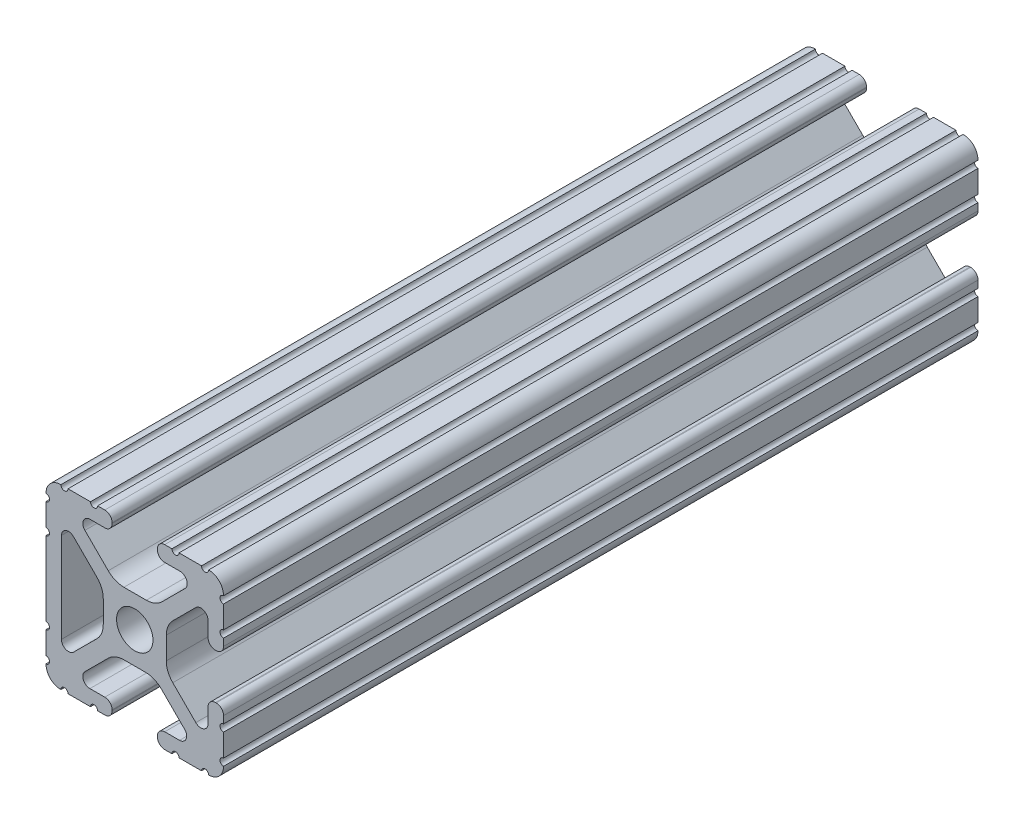
from build123d import *

# Parameters (mm, degrees)
SKETCH1_R           = 2.6035
BOSS_EXTRUDE1_DEPTH = 107.95


with BuildPart() as part:
    # Sketch1 → Boss-Extrude1 (new body)
    with BuildSketch(Plane(origin=(0, 0, -152.4), x_dir=(-1, 0, 0), z_dir=(0, 0, -1))):
        with BuildLine():
            Line((6.416409763, -10.4902), (4.28752, -10.4902))
            ThreePointArc((4.28752, -10.4902), (3.545750844, -10.797450844), (3.2385, -11.53922))
            Line((3.2385, -11.53922), (3.2385, -11.65098))
            ThreePointArc((3.2385, -11.65098), (3.545750844, -12.392749156), (4.28752, -12.7))
            Line((4.28752, -12.7), (5.3170836, -12.7))
            ThreePointArc((5.3170836, -12.7), (5.8250836, -12.192), (6.3330836, -12.7))
            Line((6.3330836, -12.7), (9.5504, -12.7))
            ThreePointArc((9.5504, -12.7), (10.058323491, -12.192000006), (10.566399977, -12.699846982))
            ThreePointArc((10.566399977, -12.699846982), (12.082522516, -12.082522516), (12.699846982, -10.566399977))
            ThreePointArc((12.699846982, -10.566399977), (12.192000006, -10.058323491), (12.7, -9.5504))
            Line((12.7, -9.5504), (12.7, -6.3330836))
            ThreePointArc((12.7, -6.3330836), (12.192, -5.8250836), (12.7, -5.3170836))
            Line((12.7, -5.3170836), (12.7, 5.3171344))
            ThreePointArc((12.7, 5.3171344), (12.192, 5.8251344), (12.7, 6.3331344))
            Line((12.7, 6.3331344), (12.7, 9.5504))
            ThreePointArc((12.7, 9.5504), (12.192000006, 10.058323491), (12.699846982, 10.566399977))
            ThreePointArc((12.699846982, 10.566399977), (12.082522516, 12.082522516), (10.566399977, 12.699846982))
            ThreePointArc((10.566399977, 12.699846982), (10.058323491, 12.192000006), (9.5504, 12.7))
            Line((9.5504, 12.7), (6.3331344, 12.7))
            ThreePointArc((6.3331344, 12.7), (5.8251344, 12.192), (5.3171344, 12.7))
            Line((5.3171344, 12.7), (4.2874692, 12.7))
            ThreePointArc((4.2874692, 12.7), (3.545700044, 12.392749156), (3.2384492, 11.65098))
            Line((3.2384492, 11.65098), (3.2384492, 11.53922))
            ThreePointArc((3.2384492, 11.53922), (3.545700044, 10.797450844), (4.2874692, 10.4902))
            Line((4.2874692, 10.4902), (6.416384363, 10.4902))
            ThreePointArc((6.416384363, 10.4902), (7.355223148, 9.862578342), (7.134149423, 8.755124678))
            Line((7.134149423, 8.755124678), (3.796632915, 5.423689619))
            ThreePointArc((3.796632915, 5.423689619), (2.767299421, 4.736928798), (1.553617102, 4.4958))
            Line((1.553617102, 4.4958), (-1.657299581, 4.4958))
            ThreePointArc((-1.657299581, 4.4958), (-2.8709819, 4.736928798), (-3.900315394, 5.423689619))
            Line((-3.900315394, 5.423689619), (-7.207191475, 8.724540082))
            ThreePointArc((-7.207191475, 8.724540082), (-7.43216212, 9.851515102), (-6.476774195, 10.4902))
            Line((-6.476774195, 10.4902), (-4.2874692, 10.4902))
            ThreePointArc((-4.2874692, 10.4902), (-3.545700044, 10.797450844), (-3.2384492, 11.53922))
            Line((-3.2384492, 11.53922), (-3.2384492, 11.65098))
            ThreePointArc((-3.2384492, 11.65098), (-3.545700044, 12.392749156), (-4.2874692, 12.7))
            Line((-4.2874692, 12.7), (-5.3170836, 12.7))
            ThreePointArc((-5.3170836, 12.7), (-5.8250836, 12.192), (-6.3330836, 12.7))
            Line((-6.3330836, 12.7), (-9.5504, 12.7))
            ThreePointArc((-9.5504, 12.7), (-10.058323491, 12.192000006), (-10.566399977, 12.699846982))
            ThreePointArc((-10.566399977, 12.699846982), (-12.082522516, 12.082522516), (-12.699846982, 10.566399977))
            ThreePointArc((-12.699846982, 10.566399977), (-12.192000006, 10.058323491), (-12.7, 9.5504))
            Line((-12.7, 9.5504), (-12.7, 6.3331344))
            ThreePointArc((-12.7, 6.3331344), (-12.192, 5.8251344), (-12.7, 5.3171344))
            Line((-12.7, 5.3171344), (-12.7, 4.287470133))
            ThreePointArc((-12.7, 4.287470133), (-12.392749156, 3.545700977), (-11.65098, 3.238450133))
            Line((-11.65098, 3.238450133), (-11.53922, 3.238450133))
            ThreePointArc((-11.53922, 3.238450133), (-10.797450844, 3.545700977), (-10.4902, 4.287470133))
            Line((-10.4902, 4.287470133), (-10.4902, 6.402089023))
            ThreePointArc((-10.4902, 6.402089023), (-9.856394933, 7.351113629), (-8.736962546, 7.129240479))
            Line((-8.736962546, 7.129240479), (-5.440484187, 3.838768792))
            ThreePointArc((-5.440484187, 3.838768792), (-4.75073678, 2.808015636), (-4.5085, 1.591658411))
            Line((-4.5085, 1.591658411), (-4.5085, -1.591658411))
            ThreePointArc((-4.5085, -1.591658411), (-4.75073678, -2.808015636), (-5.440484187, -3.838768792))
            Line((-5.440484187, -3.838768792), (-8.736962546, -7.129240479))
            ThreePointArc((-8.736962546, -7.129240479), (-9.856394933, -7.351113629), (-10.4902, -6.402089023))
            Line((-10.4902, -6.402089023), (-10.4902, -4.287470133))
            ThreePointArc((-10.4902, -4.287470133), (-10.797450844, -3.545700977), (-11.53922, -3.238450133))
            Line((-11.53922, -3.238450133), (-11.65098, -3.238450133))
            ThreePointArc((-11.65098, -3.238450133), (-12.392749156, -3.545700977), (-12.7, -4.287470133))
            Line((-12.7, -4.287470133), (-12.7, -5.3170836))
            ThreePointArc((-12.7, -5.3170836), (-12.192, -5.8250836), (-12.7, -6.3330836))
            Line((-12.7, -6.3330836), (-12.7, -9.5504))
            ThreePointArc((-12.7, -9.5504), (-12.192000006, -10.058323491), (-12.699846982, -10.566399977))
            ThreePointArc((-12.699846982, -10.566399977), (-12.082522516, -12.082522516), (-10.566399977, -12.699846982))
            ThreePointArc((-10.566399977, -12.699846982), (-10.058323491, -12.192000006), (-9.5504, -12.7))
            Line((-9.5504, -12.7), (-6.3331344, -12.7))
            ThreePointArc((-6.3331344, -12.7), (-5.8251344, -12.192), (-5.3171344, -12.7))
            Line((-5.3171344, -12.7), (-4.28752, -12.7))
            ThreePointArc((-4.28752, -12.7), (-3.545750844, -12.392749156), (-3.2385, -11.65098))
            Line((-3.2385, -11.65098), (-3.2385, -11.53922))
            ThreePointArc((-3.2385, -11.53922), (-3.545750844, -10.797450844), (-4.28752, -10.4902))
            Line((-4.28752, -10.4902), (-6.40834956, -10.4902))
            ThreePointArc((-6.40834956, -10.4902), (-7.350269456, -9.860518594), (-7.128470204, -8.749430454))
            Line((-7.128470204, -8.749430454), (-3.796658315, -5.423689619))
            ThreePointArc((-3.796658315, -5.423689619), (-2.767324821, -4.736928798), (-1.553642502, -4.4958))
            Line((-1.553642502, -4.4958), (1.553642502, -4.4958))
            ThreePointArc((1.553642502, -4.4958), (2.767324821, -4.736928798), (3.796658315, -5.423689619))
            Line((3.796658315, -5.423689619), (7.134174823, -8.755124678))
            ThreePointArc((7.134174823, -8.755124678), (7.355248548, -9.862578342), (6.416409763, -10.4902))
        make_face()
        Circle(SKETCH1_R, mode=Mode.SUBTRACT)
        with BuildLine():
            Line((10.4902, 6.446436794), (10.4902, -6.425372487))
            ThreePointArc((10.4902, -6.425372487), (9.862352148, -7.36547709), (8.753441447, -7.145689354))
            Line((8.753441447, -7.145689354), (5.440484187, -3.838768792))
            ThreePointArc((5.440484187, -3.838768792), (4.75073678, -2.808015636), (4.5085, -1.591658411))
            Line((4.5085, -1.591658411), (4.5085, 1.591658411))
            ThreePointArc((4.5085, 1.591658411), (4.75073678, 2.808015636), (5.440484187, 3.838768792))
            Line((5.440484187, 3.838768792), (8.768349738, 7.160570479))
            ThreePointArc((8.768349738, 7.160570479), (9.867741577, 7.378471563), (10.4902, 6.446436794))
        make_face(mode=Mode.SUBTRACT)
    extrude(amount=-BOSS_EXTRUDE1_DEPTH)


solid = part.part
